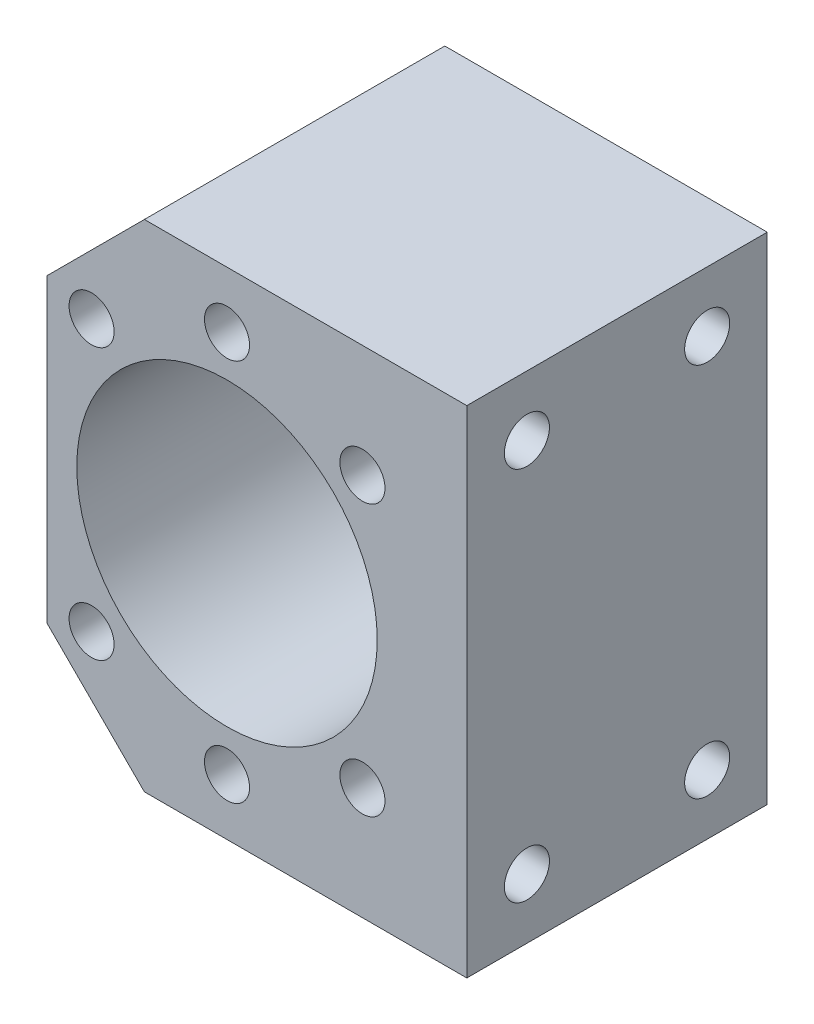
from build123d import *

# Parameters (mm, degrees)
SKETCH1_R           = 20
BOSS_EXTRUDE2_DEPTH = 40
SKETCH8_R           = 3
CUT_EXTRUDE1_DEPTH  = 16
SKETCH9_R           = 3
CUT_EXTRUDE2_DEPTH  = 16


with BuildPart() as part:
    # Sketch1 → Boss-Extrude2 (new body)
    with BuildSketch(Plane.XY):
        Polygon((-24, -20), (-11, -33), (31.93, -33), (31.93, 33), (-11, 33), (-24, 20), align=None)
        Circle(SKETCH1_R, mode=Mode.SUBTRACT)
    extrude(amount=BOSS_EXTRUDE2_DEPTH)

    # Sketch8 → Cut-Extrude1 (cut)
    with BuildSketch(Plane.XY.offset(40)):
        with Locations((0, 25.5)):
            Circle(SKETCH8_R)
        with Locations((18.03122292, 18.03122292)):
            Circle(SKETCH8_R)
        with Locations((18.03122292, -18.03122292)):
            Circle(SKETCH8_R)
        with Locations((0, -25.5)):
            Circle(SKETCH8_R)
        with Locations((-18.03122292, -18.03122292)):
            Circle(SKETCH8_R)
        with Locations((-18.03122292, 18.03122292)):
            Circle(SKETCH8_R)
    extrude(amount=-CUT_EXTRUDE1_DEPTH, mode=Mode.SUBTRACT)

    # Sketch9 → Cut-Extrude2 (cut)
    with BuildSketch(Plane(origin=(31.93, 0, 0), x_dir=(0, 0, -1), z_dir=(1, 0, 0))):
        with Locations((-32, 25)):
            Circle(SKETCH9_R)
        with Locations((-8, 25)):
            Circle(SKETCH9_R)
        with Locations((-8, -25)):
            Circle(SKETCH9_R)
        with Locations((-32, -25)):
            Circle(SKETCH9_R)
    extrude(amount=-CUT_EXTRUDE2_DEPTH, mode=Mode.SUBTRACT)


solid = part.part
